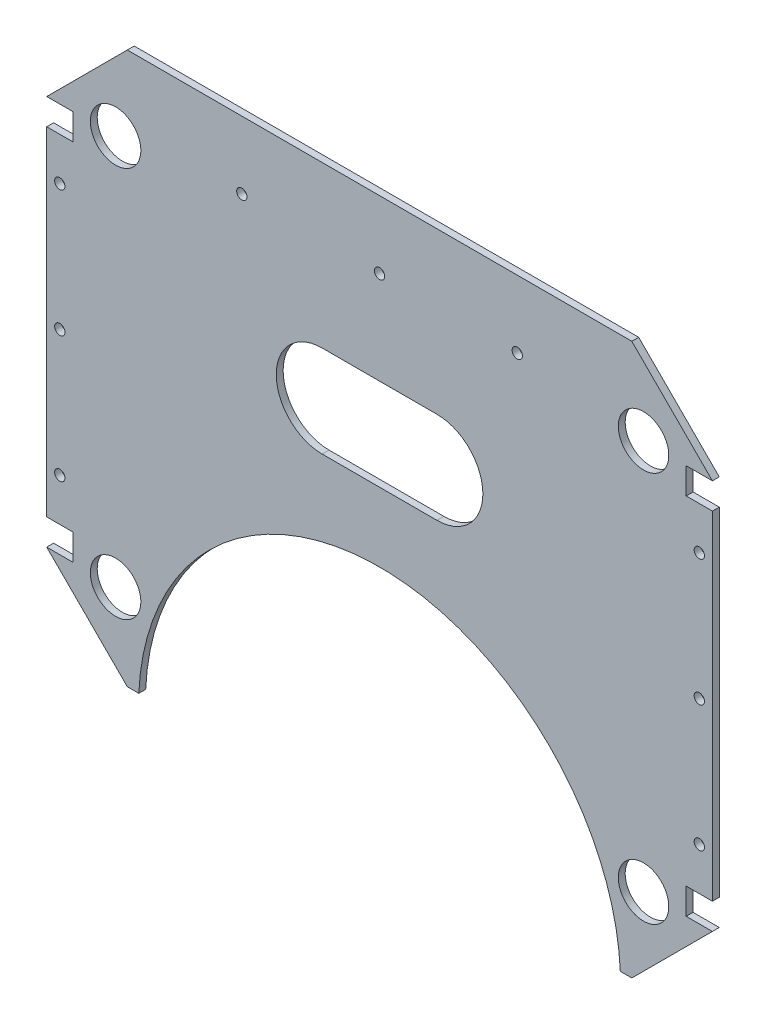
from build123d import *

# Parameters (mm, degrees)
BOSS_EXTRU_1_DEPTH      = 3
ESQUISSE21_W            = 11.4
ESQUISSE21_H            = 11.4
ENL_V_MAT_EXTRU_3_DEPTH = 4
D_GAGEMENT_M41_D        = 4.5
D_GAGEMENT_M42_D        = 4.5
D_GAGEMENT_M201_D       = 22
ENL_V_MAT_EXTRU_4_DEPTH = 4


with BuildPart() as part:
    # Esquisse1 → Boss.-Extru.1 (new body)
    with BuildSketch(Plane.XY):
        with BuildLine():
            Line((-145, 85), (-109.886246, 120.113754))
            Line((-109.886246, 120.113754), (109.886246, 120.113754))
            Line((109.886246, 120.113754), (145, 85))
            Line((145, 85), (145, -85))
            Line((145, -85), (109.886246, -120.113754))
            Line((109.886246, -120.113754), (104.886246, -120.113754))
            ThreePointArc((104.886246, -120.113754), (0, -20), (-104.886246, -120.113754))
            Line((-104.886246, -120.113754), (-109.886246, -120.113754))
            Line((-109.886246, -120.113754), (-145, -85))
            Line((-145, -85), (-145, 85))
        make_face()
    extrude(amount=BOSS_EXTRU_1_DEPTH)

    # Esquisse21 → Enlèv. mat.-Extru.3 (cut, through all)
    with BuildSketch(Plane.XY.offset(3)):
        with Locations((-139.3, 79.3)):
            Rectangle(ESQUISSE21_W, ESQUISSE21_H)
        with Locations((139.3, 79.3)):
            Rectangle(ESQUISSE21_W, ESQUISSE21_H)
        with Locations((-139.3, -79.3)):
            Rectangle(ESQUISSE21_W, ESQUISSE21_H)
        with Locations((139.3, -79.3)):
            Rectangle(ESQUISSE21_W, ESQUISSE21_H)
    extrude(amount=-ENL_V_MAT_EXTRU_3_DEPTH, mode=Mode.SUBTRACT)

    # Dégagement M41 (through all)
    with Locations(Plane(origin=(0, 0, 0), x_dir=(-1, 0, 0), z_dir=(0, 0, -1))):
        with Locations((-139.3, 55), (-139.3, 0), (-139.3, -55), (139.3, 55), (139.3, 0), (139.3, -55)):
            Hole(D_GAGEMENT_M41_D / 2)

    # Dégagement M42 (through all)
    with Locations(Plane.XY.offset(3)):
        with Locations((-60, 90.713754), (0, 90.713754), (60, 90.713754)):
            Hole(D_GAGEMENT_M42_D / 2)

    # Dégagement M201 (through all)
    with Locations(Plane(origin=(0, 0, 0), x_dir=(-1, 0, 0), z_dir=(0, 0, -1))):
        with Locations((-115, 85.113754), (-115, -85.113754), (115, 85.113754), (115, -85.113754)):
            Hole(D_GAGEMENT_M201_D / 2)

    # Esquisse46 → Enlèv. mat.-Extru.4 (cut, through all)
    with BuildSketch(Plane(origin=(0, 0, 0), x_dir=(-1, 0, 0), z_dir=(0, 0, -1))):
        with BuildLine():
            Line((-25, 50.113754), (25, 50.113754))
            ThreePointArc((25, 50.113754), (45, 30.113754), (25, 10.113754))
            Line((25, 10.113754), (-25, 10.113754))
            ThreePointArc((-25, 10.113754), (-45, 30.113754), (-25, 50.113754))
        make_face()
    extrude(amount=-ENL_V_MAT_EXTRU_4_DEPTH, mode=Mode.SUBTRACT)


solid = part.part
